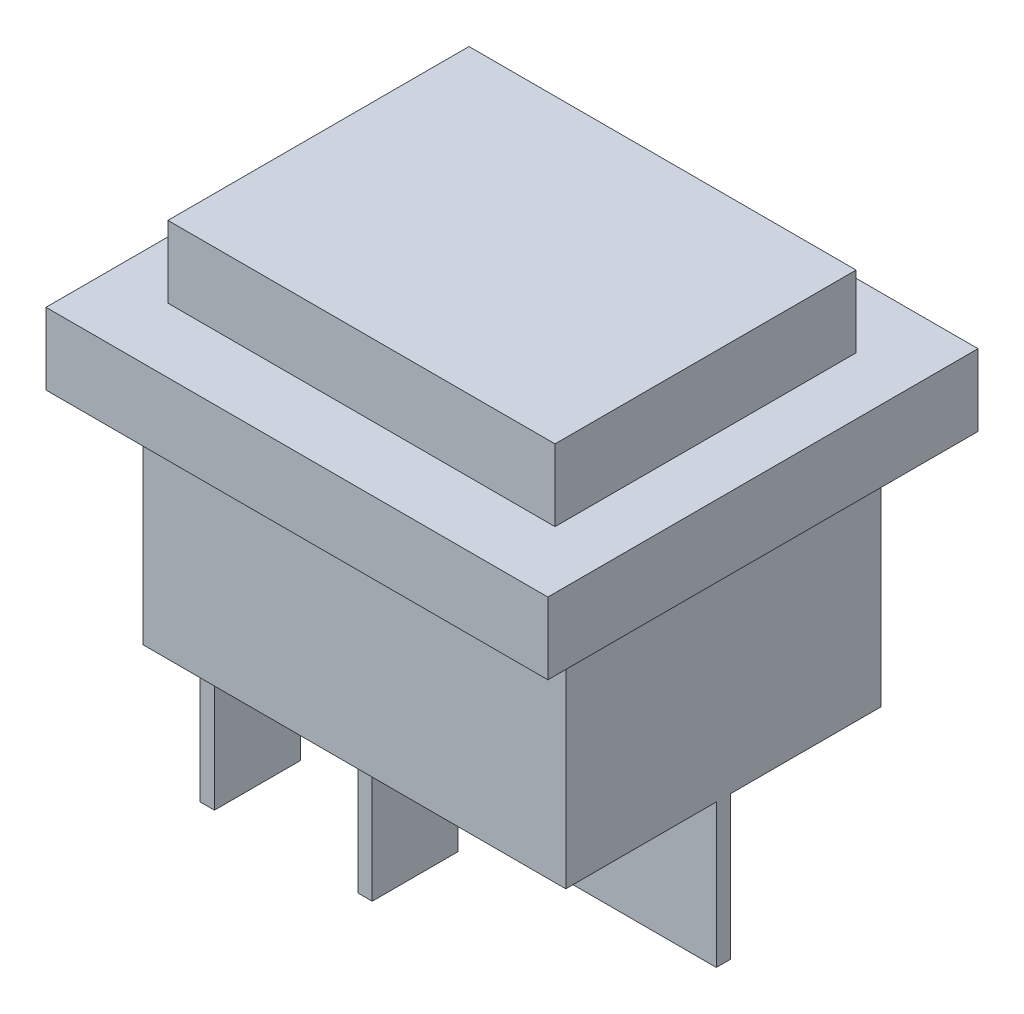
from build123d import *

# Parameters (mm, degrees)
SKETCH_1_W      = 29.5
SKETCH_1_H      = 22
EXTRUDE_1_DEPTH = 16
SKETCH_2_W      = 35
SKETCH_2_H      = 30
EXTRUDE_2_DEPTH = 5
SKETCH_3_W      = 27
SKETCH_3_H      = 21
EXTRUDE_3_DEPTH = 5
SKETCH_4_W      = 29.5
SKETCH_4_H      = 1
SKETCH_4_W_2    = 1
SKETCH_4_H_2    = 6
EXTRUDE_4_DEPTH = 10


with BuildPart() as part:
    # Эскиз1 → Бобышка-Вытянуть1 (new body)
    with BuildSketch(Plane(origin=(0, 0, 0), x_dir=(1, 0, 0), z_dir=(0, 1, 0))):
        Rectangle(SKETCH_1_W, SKETCH_1_H)
    extrude(amount=-EXTRUDE_1_DEPTH)

    # Эскиз2 → Бобышка-Вытянуть2 (add)
    with BuildSketch(Plane(origin=(0, 0, 0), x_dir=(1, 0, 0), z_dir=(0, 1, 0))):
        Rectangle(SKETCH_2_W, SKETCH_2_H)
    extrude(amount=EXTRUDE_2_DEPTH)

    # Эскиз3 → Бобышка-Вытянуть3 (add)
    with BuildSketch(Plane(origin=(0, 5, 0), x_dir=(1, 0, 0), z_dir=(0, 1, 0))):
        Rectangle(SKETCH_3_W, SKETCH_3_H)
    extrude(amount=EXTRUDE_3_DEPTH)

    # Эскиз4 → Бобышка-Вытянуть4 (add)
    with BuildSketch(Plane.XZ.offset(16)):
        Rectangle(SKETCH_4_W, SKETCH_4_H)
        with Locations((-12.75, 5.5)):
            Rectangle(SKETCH_4_W_2, SKETCH_4_H_2)
        with Locations((-1.75, 5.5)):
            Rectangle(SKETCH_4_W_2, SKETCH_4_H_2)
        with Locations((-12.75, -5.5)):
            Rectangle(SKETCH_4_W_2, SKETCH_4_H_2)
        with Locations((-1.75, -5.5)):
            Rectangle(SKETCH_4_W_2, SKETCH_4_H_2)
    extrude(amount=EXTRUDE_4_DEPTH)


solid = part.part
